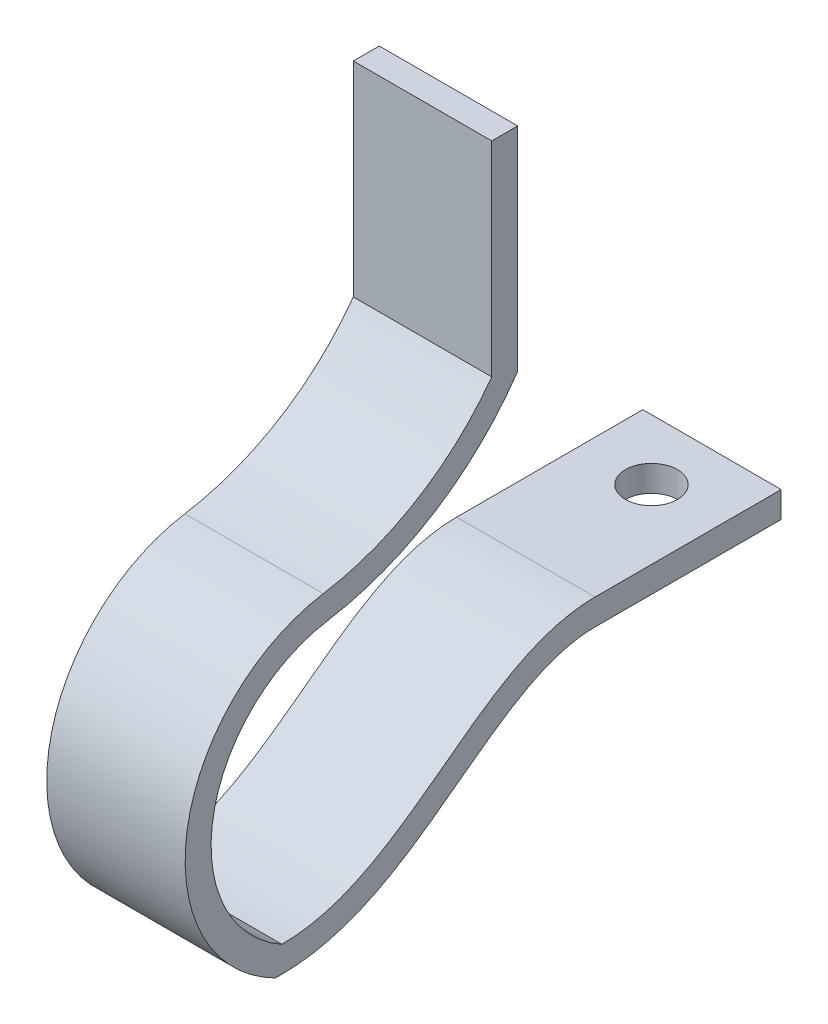
from build123d import *

# Parameters (mm, degrees)
BOSS_EXTRUDE1_DEPTH = 4.064
SKETCH2_R           = 0.762
CUT_EXTRUDE1_DEPTH  = 5.996401933


with BuildPart() as part:
    # Sketch1 → Boss-Extrude1 (new body)
    with BuildSketch(Plane(origin=(0, 0, 0), x_dir=(0, 0, -1), z_dir=(1, 0, 0))):
        with BuildLine():
            Line((4.726865031, 5.556764983), (4.726865031, -0.444820699))
            ThreePointArc((4.726865031, -0.444820699), (2.554182799, -2.454658405), (-0.22039607, -3.485050462))
            ThreePointArc((-0.22039607, -3.485050462), (-4.22007249, -7.510942511), (-1.625042246, -12.557826332))
            Line((-1.625042246, -12.557826332), (-1.435472167, -12.557826332))
            add(Edge.make_bspline(
                [(-1.435472167, -12.557826332), (-1.175924208, -12.557849399), (-0.648911083, -12.519392405), (0.32614537, -12.308921718), (1.440239513, -11.841665003), (2.626862444, -11.096563597), (4.080334858, -10.011065793), (5.769221033, -8.746934213), (7.066078237, -8.323424357), (7.761067398, -8.323424519)],
                knots=[0, 0, 0, 0, 0.054765757, 0.109531513, 0.219063026, 0.328594539, 0.438126053, 0.657189079, 0.876252105, 0.876252105, 0.876252105, 0.876252105], degree=3))
            Line((7.761067398, -8.323424519), (13.22812784, -8.323424519))
            Line((13.22812784, -8.323424519), (13.22812784, -7.561424519))
            Line((13.22812784, -7.561424519), (7.761067576, -7.561424519))
            add(Edge.make_bspline(
                [(-1.435404445, -11.795826335), (1.654785659, -11.796100971), (4.006866827, -8.222316999), (7.226557461, -7.561424394), (7.761067576, -7.561424519)],
                knots=[0, 0, 0, 0, 0.739499728, 0.876252105, 0.876252105, 0.876252105, 0.876252105], degree=3))
            ThreePointArc((-1.435404445, -11.795826335), (-3.452810626, -7.541681499), (-0.098895233, -4.237301448))
            ThreePointArc((-0.098895233, -4.237301448), (3.060460139, -3.036798555), (5.488865031, -0.686142637))
            Line((5.488865031, -0.686142637), (5.488865031, 5.556764983))
            Line((5.488865031, 5.556764983), (4.726865031, 5.556764983))
        make_face()
    extrude(amount=-BOSS_EXTRUDE1_DEPTH)

    # Sketch2 → Cut-Extrude1 (cut, through all)
    with BuildSketch(Plane(origin=(0, -7.561424519, 0), x_dir=(1, 0, 0), z_dir=(0, 1, 0))):
        with Locations((-2.032, 11.45012784)):
            Circle(SKETCH2_R)
    extrude(amount=-CUT_EXTRUDE1_DEPTH, mode=Mode.SUBTRACT)


solid = part.part
